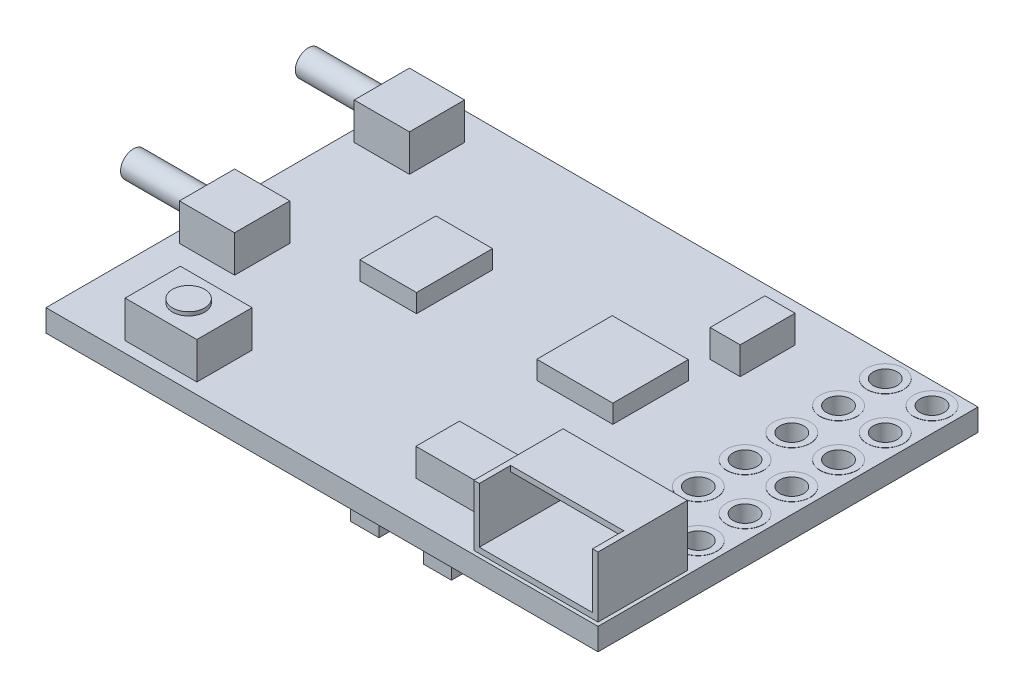
from build123d import *

# Parameters (mm, degrees)
SKETCH1_W            = 30
SKETCH1_H            = 20.65
BOSS_EXTRUDE1_DEPTH  = 1.2
CUT_EXTRUDE1_REACH   = 3.2
SKETCH2_R            = 0.65
SKETCH3_W            = 6.75
SKETCH3_H            = 4.85
BOSS_EXTRUDE2_DEPTH  = 3.3
SKETCH4_W            = 3
SKETCH4_H            = 3
BOSS_EXTRUDE3_DEPTH  = 2
SKETCH5_W            = 3.9
SKETCH5_H            = 3
BOSS_EXTRUDE4_DEPTH  = 2
SKETCH6_R            = 0.875
BOSS_EXTRUDE5_DEPTH  = 0.2
SKETCH7_W            = 6.15
SKETCH7_H            = 1.7
CUT_EXTRUDE2_DEPTH   = 3
SKETCH8_W            = 6.15
SKETCH8_H            = 2.7
CUT_EXTRUDE3_DEPTH   = 2.85
SKETCH9_W            = 4.13358082
SKETCH9_H            = 4.101537558
SKETCH9_W_2          = 3.076153169
SKETCH9_H_2          = 4.13358082
BOSS_EXTRUDE6_DEPTH  = 1
SKETCH10_W           = 1.634206371
SKETCH10_H           = 2.980023382
SKETCH10_W_2         = 4.454013442
SKETCH10_H_2         = 2.371201401
BOSS_EXTRUDE7_DEPTH  = 1.5
SKETCH11_W           = 6.849678862
SKETCH11_H           = 6.849678863
SKETCH11_W_2         = 1.518707079
SKETCH11_H_2         = 3.006420134
SKETCH11_W_3         = 1.5497011
SKETCH11_H_3         = 3.068408178
SKETCH11_W_4         = 1.177772837
SKETCH11_H_4         = 2.758467958
SKETCH11_W_5         = 2.86022906
SKETCH11_H_5         = 4.18419297
SKETCH11_W_6         = 2.386539694
SKETCH11_H_6         = 3.0994022
SKETCH11_W_7         = 1.270754903
SKETCH11_H_7         = 3.161390244
BOSS_EXTRUDE8_DEPTH  = 1.5
SKETCH12_R           = 1
SKETCH12_R_2         = 0.65
BOSS_EXTRUDE9_DEPTH  = 0.01
SKETCH13_R           = 0.7
BOSS_EXTRUDE10_DEPTH = 4


with BuildPart() as part:
    # Sketch1 → Boss-Extrude1 (new body)
    with BuildSketch(Plane(origin=(0, 0, 0), x_dir=(1, 0, 0), z_dir=(0, 1, 0))):
        Rectangle(SKETCH1_W, SKETCH1_H)
    extrude(amount=BOSS_EXTRUDE1_DEPTH)

    # Sketch2 → Cut-Extrude1 (cut, up to next)
    with BuildSketch(Plane(origin=(0, 1.2, 0), x_dir=(1, 0, 0), z_dir=(0, 1, 0)), mode=Mode.PRIVATE) as cut_extrude1_sk1:
        with Locations((13.7, 9.125)):
            Circle(SKETCH2_R)
    cut_extrude1_tool1 = extrude(cut_extrude1_sk1.sketch, amount=-CUT_EXTRUDE1_REACH, mode=Mode.PRIVATE) & part.part
    add(cut_extrude1_tool1.solids().sort_by_distance((13.7, 1.2, -9.125))[0], mode=Mode.SUBTRACT)
    # Sketch2 → Cut-Extrude1 (cut, up to next)
    with BuildSketch(Plane(origin=(0, 1.2, 0), x_dir=(1, 0, 0), z_dir=(0, 1, 0)), mode=Mode.PRIVATE) as cut_extrude1_sk2:
        with Locations((11.16, 9.125)):
            Circle(SKETCH2_R)
    cut_extrude1_tool2 = extrude(cut_extrude1_sk2.sketch, amount=-CUT_EXTRUDE1_REACH, mode=Mode.PRIVATE) & part.part
    add(cut_extrude1_tool2.solids().sort_by_distance((11.16, 1.2, -9.125))[0], mode=Mode.SUBTRACT)
    # Sketch2 → Cut-Extrude1 (cut, up to next)
    with BuildSketch(Plane(origin=(0, 1.2, 0), x_dir=(1, 0, 0), z_dir=(0, 1, 0)), mode=Mode.PRIVATE) as cut_extrude1_sk3:
        with Locations((11.16, 6.585)):
            Circle(SKETCH2_R)
    cut_extrude1_tool3 = extrude(cut_extrude1_sk3.sketch, amount=-CUT_EXTRUDE1_REACH, mode=Mode.PRIVATE) & part.part
    add(cut_extrude1_tool3.solids().sort_by_distance((11.16, 1.2, -6.585))[0], mode=Mode.SUBTRACT)
    # Sketch2 → Cut-Extrude1 (cut, up to next)
    with BuildSketch(Plane(origin=(0, 1.2, 0), x_dir=(1, 0, 0), z_dir=(0, 1, 0)), mode=Mode.PRIVATE) as cut_extrude1_sk4:
        with Locations((11.16, 4.045)):
            Circle(SKETCH2_R)
    cut_extrude1_tool4 = extrude(cut_extrude1_sk4.sketch, amount=-CUT_EXTRUDE1_REACH, mode=Mode.PRIVATE) & part.part
    add(cut_extrude1_tool4.solids().sort_by_distance((11.16, 1.2, -4.045))[0], mode=Mode.SUBTRACT)
    # Sketch2 → Cut-Extrude1 (cut, up to next)
    with BuildSketch(Plane(origin=(0, 1.2, 0), x_dir=(1, 0, 0), z_dir=(0, 1, 0)), mode=Mode.PRIVATE) as cut_extrude1_sk5:
        with Locations((11.16, 1.505)):
            Circle(SKETCH2_R)
    cut_extrude1_tool5 = extrude(cut_extrude1_sk5.sketch, amount=-CUT_EXTRUDE1_REACH, mode=Mode.PRIVATE) & part.part
    add(cut_extrude1_tool5.solids().sort_by_distance((11.16, 1.2, -1.505))[0], mode=Mode.SUBTRACT)
    # Sketch2 → Cut-Extrude1 (cut, up to next)
    with BuildSketch(Plane(origin=(0, 1.2, 0), x_dir=(1, 0, 0), z_dir=(0, 1, 0)), mode=Mode.PRIVATE) as cut_extrude1_sk6:
        with Locations((11.16, -1.035)):
            Circle(SKETCH2_R)
    cut_extrude1_tool6 = extrude(cut_extrude1_sk6.sketch, amount=-CUT_EXTRUDE1_REACH, mode=Mode.PRIVATE) & part.part
    add(cut_extrude1_tool6.solids().sort_by_distance((11.16, 1.2, 1.035))[0], mode=Mode.SUBTRACT)
    # Sketch2 → Cut-Extrude1 (cut, up to next)
    with BuildSketch(Plane(origin=(0, 1.2, 0), x_dir=(1, 0, 0), z_dir=(0, 1, 0)), mode=Mode.PRIVATE) as cut_extrude1_sk7:
        with Locations((11.16, -3.575)):
            Circle(SKETCH2_R)
    cut_extrude1_tool7 = extrude(cut_extrude1_sk7.sketch, amount=-CUT_EXTRUDE1_REACH, mode=Mode.PRIVATE) & part.part
    add(cut_extrude1_tool7.solids().sort_by_distance((11.16, 1.2, 3.575))[0], mode=Mode.SUBTRACT)
    # Sketch2 → Cut-Extrude1 (cut, up to next)
    with BuildSketch(Plane(origin=(0, 1.2, 0), x_dir=(1, 0, 0), z_dir=(0, 1, 0)), mode=Mode.PRIVATE) as cut_extrude1_sk8:
        with Locations((13.7, 6.585)):
            Circle(SKETCH2_R)
    cut_extrude1_tool8 = extrude(cut_extrude1_sk8.sketch, amount=-CUT_EXTRUDE1_REACH, mode=Mode.PRIVATE) & part.part
    add(cut_extrude1_tool8.solids().sort_by_distance((13.7, 1.2, -6.585))[0], mode=Mode.SUBTRACT)
    # Sketch2 → Cut-Extrude1 (cut, up to next)
    with BuildSketch(Plane(origin=(0, 1.2, 0), x_dir=(1, 0, 0), z_dir=(0, 1, 0)), mode=Mode.PRIVATE) as cut_extrude1_sk9:
        with Locations((13.7, 4.045)):
            Circle(SKETCH2_R)
    cut_extrude1_tool9 = extrude(cut_extrude1_sk9.sketch, amount=-CUT_EXTRUDE1_REACH, mode=Mode.PRIVATE) & part.part
    add(cut_extrude1_tool9.solids().sort_by_distance((13.7, 1.2, -4.045))[0], mode=Mode.SUBTRACT)
    # Sketch2 → Cut-Extrude1 (cut, up to next)
    with BuildSketch(Plane(origin=(0, 1.2, 0), x_dir=(1, 0, 0), z_dir=(0, 1, 0)), mode=Mode.PRIVATE) as cut_extrude1_sk10:
        with Locations((13.7, 1.505)):
            Circle(SKETCH2_R)
    cut_extrude1_tool10 = extrude(cut_extrude1_sk10.sketch, amount=-CUT_EXTRUDE1_REACH, mode=Mode.PRIVATE) & part.part
    add(cut_extrude1_tool10.solids().sort_by_distance((13.7, 1.2, -1.505))[0], mode=Mode.SUBTRACT)
    # Sketch2 → Cut-Extrude1 (cut, up to next)
    with BuildSketch(Plane(origin=(0, 1.2, 0), x_dir=(1, 0, 0), z_dir=(0, 1, 0)), mode=Mode.PRIVATE) as cut_extrude1_sk11:
        with Locations((13.7, -1.035)):
            Circle(SKETCH2_R)
    cut_extrude1_tool11 = extrude(cut_extrude1_sk11.sketch, amount=-CUT_EXTRUDE1_REACH, mode=Mode.PRIVATE) & part.part
    add(cut_extrude1_tool11.solids().sort_by_distance((13.7, 1.2, 1.035))[0], mode=Mode.SUBTRACT)
    # Sketch2 → Cut-Extrude1 (cut, up to next)
    with BuildSketch(Plane(origin=(0, 1.2, 0), x_dir=(1, 0, 0), z_dir=(0, 1, 0)), mode=Mode.PRIVATE) as cut_extrude1_sk12:
        with Locations((13.7, -3.575)):
            Circle(SKETCH2_R)
    cut_extrude1_tool12 = extrude(cut_extrude1_sk12.sketch, amount=-CUT_EXTRUDE1_REACH, mode=Mode.PRIVATE) & part.part
    add(cut_extrude1_tool12.solids().sort_by_distance((13.7, 1.2, 3.575))[0], mode=Mode.SUBTRACT)

    # Sketch3 → Boss-Extrude2 (add)
    with BuildSketch(Plane(origin=(0, 1.2, 0), x_dir=(1, 0, 0), z_dir=(0, 1, 0))):
        with Locations((11.425, -7.7)):
            Rectangle(SKETCH3_W, SKETCH3_H)
    extrude(amount=BOSS_EXTRUDE2_DEPTH)

    # Sketch4 → Boss-Extrude3 (add)
    with BuildSketch(Plane(origin=(0, 1.2, 0), x_dir=(1, 0, 0), z_dir=(0, 1, 0))):
        with Locations((-12.9, 7.325)):
            Rectangle(SKETCH4_W, SKETCH4_H)
        with Locations((-12.9, -2.175)):
            Rectangle(SKETCH4_W, SKETCH4_H)
    extrude(amount=BOSS_EXTRUDE3_DEPTH)

    # Sketch5 → Boss-Extrude4 (add)
    with BuildSketch(Plane(origin=(0, 1.2, 0), x_dir=(1, 0, 0), z_dir=(0, 1, 0))):
        with Locations((-9.35, -8.225)):
            Rectangle(SKETCH5_W, SKETCH5_H)
    extrude(amount=BOSS_EXTRUDE4_DEPTH)

    # Sketch6 → Boss-Extrude5 (add)
    with BuildSketch(Plane(origin=(0, 3.2, 0), x_dir=(1, 0, 0), z_dir=(0, 1, 0))):
        with Locations((-9.35, -8.225)):
            Circle(SKETCH6_R)
    extrude(amount=BOSS_EXTRUDE5_DEPTH)

    # Sketch7 → Cut-Extrude2 (cut)
    with BuildSketch(Plane(origin=(0, 4.5, 0), x_dir=(1, 0, 0), z_dir=(0, 1, 0))):
        with Locations((11.425, -9.275)):
            Rectangle(SKETCH7_W, SKETCH7_H)
    extrude(amount=-CUT_EXTRUDE2_DEPTH, mode=Mode.SUBTRACT)

    # Sketch8 → Cut-Extrude3 (cut)
    with BuildSketch(Plane.XY.offset(8.425)):
        with Locations((11.425, 2.85)):
            Rectangle(SKETCH8_W, SKETCH8_H)
    extrude(amount=-CUT_EXTRUDE3_DEPTH, mode=Mode.SUBTRACT)

    # Sketch9 → Boss-Extrude6 (add)
    with BuildSketch(Plane(origin=(0, 1.2, 0), x_dir=(1, 0, 0), z_dir=(0, 1, 0))):
        with Locations((3.82916983, 1.634206371)):
            Rectangle(SKETCH9_W, SKETCH9_H)
        with Locations((-6.1843496, 1.522054953)):
            Rectangle(SKETCH9_W_2, SKETCH9_H_2)
    extrude(amount=BOSS_EXTRUDE6_DEPTH)

    # Sketch10 → Boss-Extrude7 (add)
    with BuildSketch(Plane(origin=(0, 1.2, 0), x_dir=(1, 0, 0), z_dir=(0, 1, 0))):
        with Locations((6.296501018, 6.77714995)):
            Rectangle(SKETCH10_W, SKETCH10_H)
        with Locations((5.30315989, -7.113604202)):
            Rectangle(SKETCH10_W_2, SKETCH10_H_2)
    extrude(amount=BOSS_EXTRUDE7_DEPTH)

    # Sketch11 → Boss-Extrude8 (add)
    with BuildSketch(Plane.XZ):
        with Locations((-2.928935079, -0.803882292)):
            Rectangle(SKETCH11_W, SKETCH11_H)
        with Locations((5.387348503, 7.936431913)):
            Rectangle(SKETCH11_W_2, SKETCH11_H_2)
        with Locations((1.404616675, 7.874443869)):
            Rectangle(SKETCH11_W_3, SKETCH11_H_3)
        with Locations((5.557815623, 4.248143295)):
            Rectangle(SKETCH11_W_4, SKETCH11_H_4)
        with Locations((-13.56988547, -6.475788318)):
            Rectangle(SKETCH11_W_5, SKETCH11_H_5)
        with Locations((-12.403220127, 2.249028876)):
            Rectangle(SKETCH11_W_6, SKETCH11_H_6)
        with Locations((-9.365805971, -7.886016319)):
            Rectangle(SKETCH11_W_7, SKETCH11_H_7)
    extrude(amount=BOSS_EXTRUDE8_DEPTH)

    # Sketch12 → Boss-Extrude9 (add)
    with BuildSketch(Plane(origin=(0, 1.2, 0), x_dir=(1, 0, 0), z_dir=(0, 1, 0))):
        with Locations((11.16, 9.125)):
            Circle(SKETCH12_R)
        with Locations((11.16, 9.125)):
            Circle(SKETCH12_R_2, mode=Mode.SUBTRACT)
        with Locations((13.7, 9.125)):
            Circle(SKETCH12_R)
        with Locations((13.7, 9.125)):
            Circle(SKETCH12_R_2, mode=Mode.SUBTRACT)
        with Locations((13.7, 6.585)):
            Circle(SKETCH12_R)
        with Locations((13.7, 6.585)):
            Circle(SKETCH12_R_2, mode=Mode.SUBTRACT)
        with Locations((11.16, 6.585)):
            Circle(SKETCH12_R)
        with Locations((11.16, 6.585)):
            Circle(SKETCH12_R_2, mode=Mode.SUBTRACT)
        with Locations((11.16, 4.045)):
            Circle(SKETCH12_R)
        with Locations((11.16, 4.045)):
            Circle(SKETCH12_R_2, mode=Mode.SUBTRACT)
        with Locations((13.7, 4.045)):
            Circle(SKETCH12_R)
        with Locations((13.7, 4.045)):
            Circle(SKETCH12_R_2, mode=Mode.SUBTRACT)
        with Locations((13.7, 1.505)):
            Circle(SKETCH12_R)
        with Locations((13.7, 1.505)):
            Circle(SKETCH12_R_2, mode=Mode.SUBTRACT)
        with Locations((11.16, 1.505)):
            Circle(SKETCH12_R)
        with Locations((11.16, 1.505)):
            Circle(SKETCH12_R_2, mode=Mode.SUBTRACT)
        with Locations((11.16, -1.035)):
            Circle(SKETCH12_R)
        with Locations((11.16, -1.035)):
            Circle(SKETCH12_R_2, mode=Mode.SUBTRACT)
        with Locations((11.16, -3.575)):
            Circle(SKETCH12_R)
        with Locations((11.16, -3.575)):
            Circle(SKETCH12_R_2, mode=Mode.SUBTRACT)
        with Locations((13.7, -3.575)):
            Circle(SKETCH12_R)
        with Locations((13.7, -3.575)):
            Circle(SKETCH12_R_2, mode=Mode.SUBTRACT)
        with Locations((13.7, -1.035)):
            Circle(SKETCH12_R)
        with Locations((13.7, -1.035)):
            Circle(SKETCH12_R_2, mode=Mode.SUBTRACT)
    boss_extrude9 = extrude(amount=BOSS_EXTRUDE9_DEPTH)

    # Mirror1: Boss-Extrude9 across plane
    add(boss_extrude9.mirror(Plane.ZX.offset(0.6)))

    # Sketch13 → Boss-Extrude10 (add)
    with BuildSketch(Plane.ZY.offset(14.4)):
        with Locations((-7.325, 2.2)):
            Circle(SKETCH13_R)
        with Locations((2.175, 2.2)):
            Circle(SKETCH13_R)
    extrude(amount=BOSS_EXTRUDE10_DEPTH)


solid = part.part
